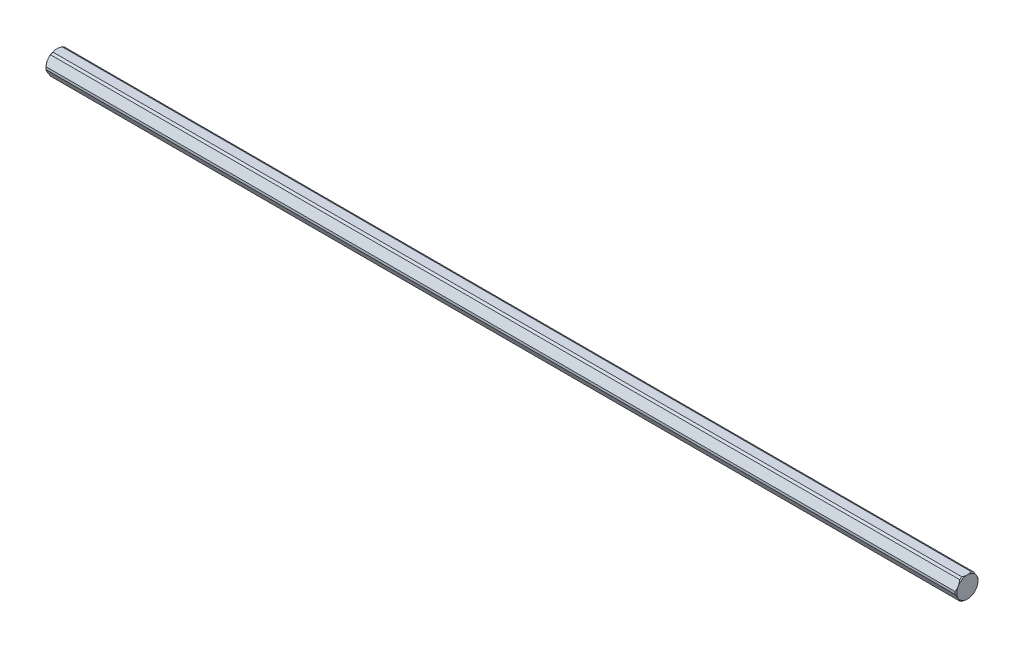
from build123d import *

# Parameters (mm, degrees)
BOSS_EXTRUDE1_DEPTH = 237


with BuildPart() as part:
    # Sketch1 → Boss-Extrude1 (new body)
    with BuildSketch(Plane(origin=(0, 0, 0), x_dir=(0, 0, -1), z_dir=(1, 0, 0))):
        with BuildLine():
            Line((2.397915762, 5.5), (-2.397915762, 5.5))
            ThreePointArc((-2.397915762, 5.5), (-3, 5.196152423), (-3.56418184, 4.826655966))
            Line((-3.56418184, 4.826655966), (-5.962097602, 0.673344034))
            ThreePointArc((-5.962097602, 0.673344034), (-6, 0), (-5.962097602, -0.673344034))
            Line((-5.962097602, -0.673344034), (-3.56418184, -4.826655966))
            ThreePointArc((-3.56418184, -4.826655966), (-3, -5.196152423), (-2.397915762, -5.5))
            Line((-2.397915762, -5.5), (2.397915762, -5.5))
            ThreePointArc((2.397915762, -5.5), (3, -5.196152423), (3.56418184, -4.826655966))
            Line((3.56418184, -4.826655966), (5.962097602, -0.673344034))
            ThreePointArc((5.962097602, -0.673344034), (6, 0), (5.962097602, 0.673344034))
            Line((5.962097602, 0.673344034), (3.56418184, 4.826655966))
            ThreePointArc((3.56418184, 4.826655966), (3, 5.196152423), (2.397915762, 5.5))
        make_face()
    extrude(amount=BOSS_EXTRUDE1_DEPTH)

    # Sketch3 → Cut-Revolve6 (revolve, cut)
    with BuildSketch(Plane(origin=(0, 0, 0), x_dir=(1, 0, 0), z_dir=(0, 1, 0))):
        Polygon((236.5, -6), (237, -6), (237, -5.5), align=None)
    revolve(axis=Axis((0, 0, 0), (1, 0, 0)), mode=Mode.SUBTRACT)

    # Mirror1: part across plane


with BuildPart() as part_1:
    add(part.part)
    add(part.part.mirror(Plane(origin=(0, 0, 0), x_dir=(0, 0, 1), z_dir=(1, 0, 0))))


solid = part_1.part
